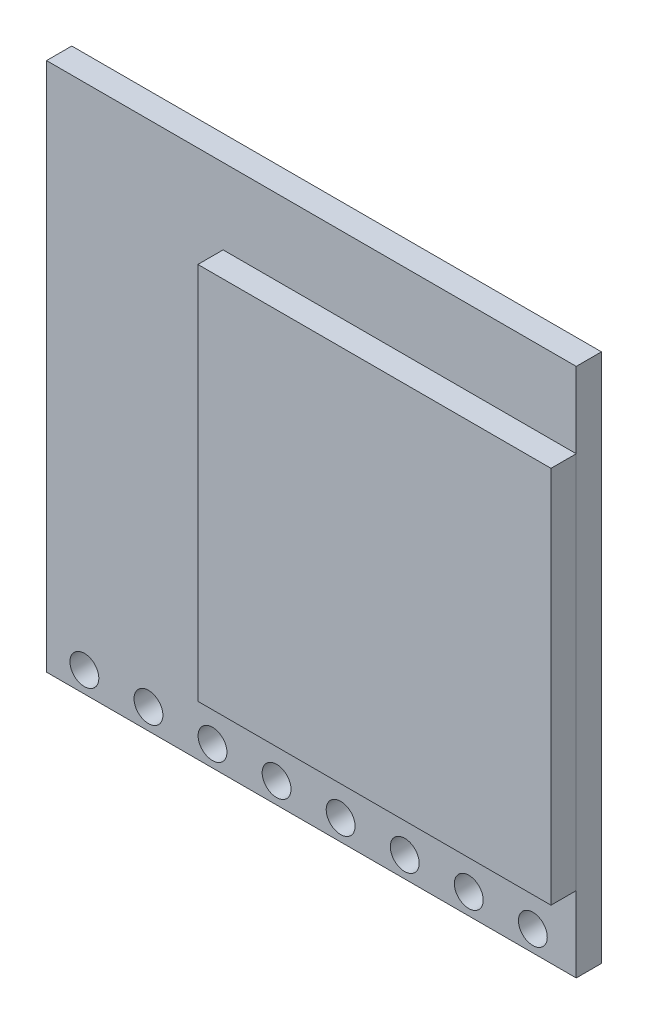
from build123d import *

# Parameters (mm, degrees)
SKETCH1_W           = 21
SKETCH1_H           = 21
BOSS_EXTRUDE1_DEPTH = 1
SKETCH2_W           = 14
SKETCH2_H           = 15
BOSS_EXTRUDE2_DEPTH = 1
SKETCH3_R           = 0.571967696
CUT_EXTRUDE1_DEPTH  = 1
LPATTERN1_COUNT     = 8
LPATTERN1_PITCH     = 2.54


with BuildPart() as part:
    # Sketch1 → Boss-Extrude1 (new body)
    with BuildSketch(Plane.XY):
        with Locations((10.5, 10.5)):
            Rectangle(SKETCH1_W, SKETCH1_H)
    extrude(amount=BOSS_EXTRUDE1_DEPTH)

    # Sketch3 → Cut-Extrude1 (cut)
    with BuildSketch(Plane.XY.offset(1)):
        with Locations((1.5, 0.826638996)):
            Circle(SKETCH3_R)
    cut_extrude1 = extrude(amount=-CUT_EXTRUDE1_DEPTH, mode=Mode.SUBTRACT)

    # LPattern1: Cut-Extrude1 ×8
    with Locations(*[(i * LPATTERN1_PITCH, 0, 0) for i in range(1, LPATTERN1_COUNT)]):
        add(cut_extrude1, mode=Mode.SUBTRACT)


with BuildPart() as body_2:
    # Sketch2 → Boss-Extrude2 (new body)
    with BuildSketch(Plane.XY.offset(1)):
        with Locations((14, 10.5)):
            Rectangle(SKETCH2_W, SKETCH2_H)
    extrude(amount=BOSS_EXTRUDE2_DEPTH)


solid = Compound([part.part, body_2.part])
